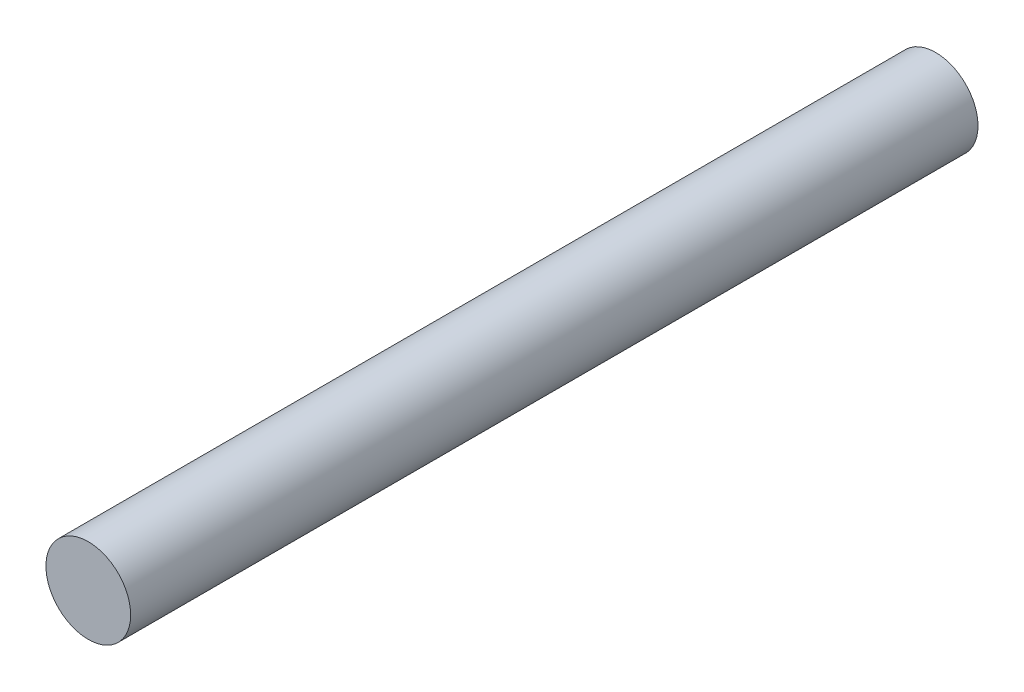
from build123d import *

# Parameters (mm, degrees)
SKETCH1_R           = 1.5
BOSS_EXTRUDE1_DEPTH = 30


with BuildPart() as part:
    # Sketch1 → Boss-Extrude1 (new body)
    with BuildSketch(Plane.XY):
        Circle(SKETCH1_R)
    extrude(amount=BOSS_EXTRUDE1_DEPTH)


solid = part.part
